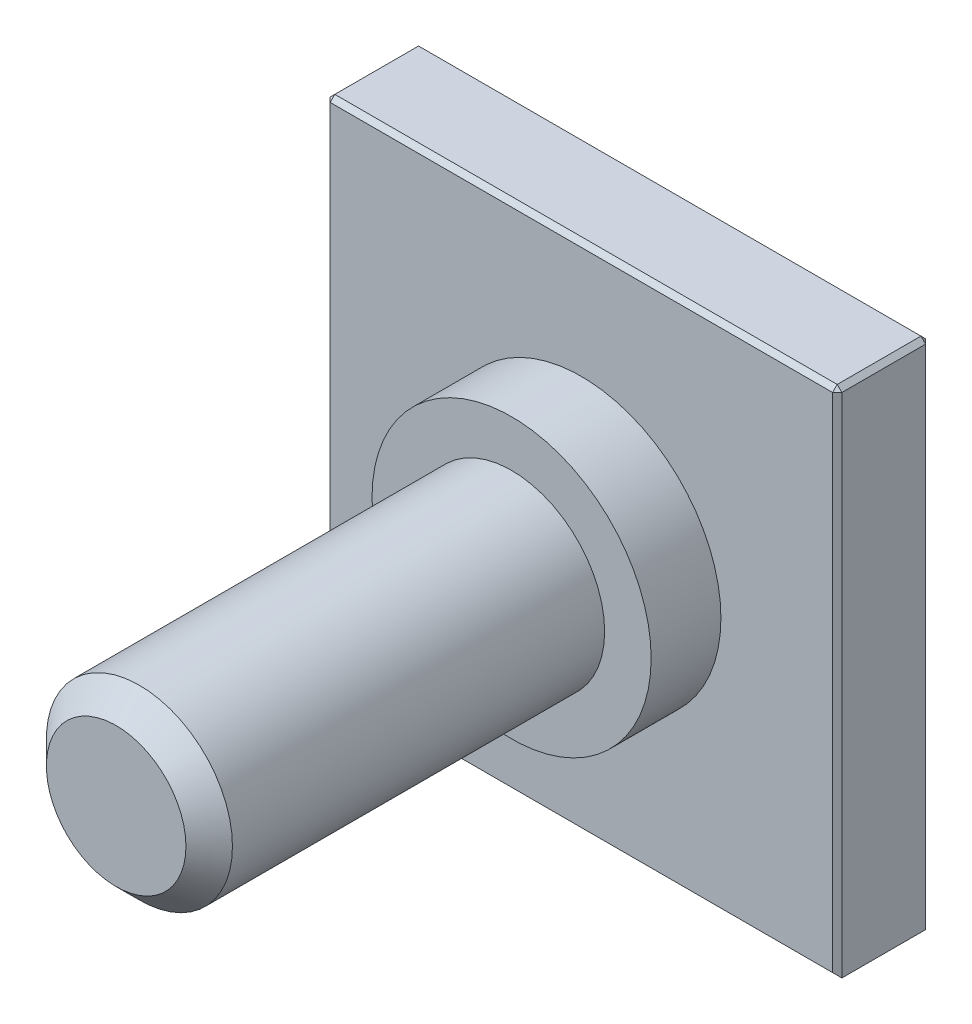
from build123d import *

# Parameters (mm, degrees)
SKETCH1_W           = 11
SKETCH1_H           = 11
BOSS_EXTRUDE1_DEPTH = 2
SKETCH2_R           = 2
BOSS_EXTRUDE2_DEPTH = 10
CHAMFER1_SIZE       = 0.1
SKETCH3_R           = 3
BOSS_EXTRUDE3_DEPTH = 1.5
CHAMFER2_SIZE       = 0.5


with BuildPart() as part:
    # Sketch1 → Boss-Extrude1 (new body)
    with BuildSketch(Plane.XY):
        Rectangle(SKETCH1_W, SKETCH1_H)
    extrude(amount=BOSS_EXTRUDE1_DEPTH)

    # Sketch2 → Boss-Extrude2 (add)
    with BuildSketch(Plane.XY.offset(2)):
        Circle(SKETCH2_R)
    extrude(amount=BOSS_EXTRUDE2_DEPTH)

    # Chamfer1
    chamfer1_edges = [part.edges().sort_by_distance(p)[0] for p in [
        (-5.5, 0, 2),
        (0, -5.5, 2),
        (5.5, 0, 2),
        (0, -5.5, 0),
        (-5.5, 0, 0),
        (0, 5.5, 0),
        (5.5, 0, 0),
        (0, 5.5, 2),
        (-5.5, 5.5, 1),
        (5.5, 5.5, 1),
    ]]
    chamfer(chamfer1_edges, length=CHAMFER1_SIZE)

    # Sketch3 → Boss-Extrude3 (add)
    with BuildSketch(Plane.XY.offset(2)):
        Circle(SKETCH3_R)
    extrude(amount=BOSS_EXTRUDE3_DEPTH)

    # Chamfer2
    chamfer2_edges = [part.edges().sort_by_distance(p)[0] for p in [
        (-2, 0, 12),
    ]]
    chamfer(chamfer2_edges, length=CHAMFER2_SIZE)


solid = part.part
